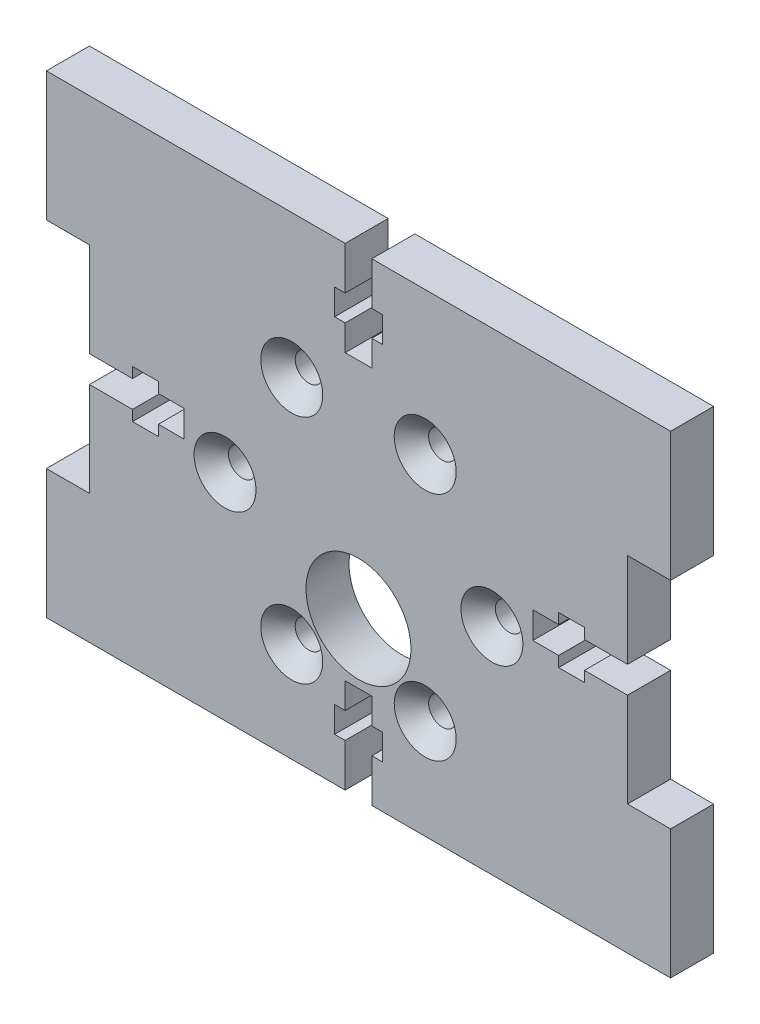
from build123d import *

# Parameters (mm, degrees)
ESQUISSE1_W                           = 26.253582595
ESQUISSE1_H                           = 55
BOSS_EXTRU_1_DEPTH                    = 5
BOSS_EXTRU_2_DEPTH                    = 5
BOSS_EXTRU_3_DEPTH                    = 5
ENL_V_MAT_EXTRU_1_DEPTH               = 5
ESQUISSE5_W                           = 5
ESQUISSE5_H                           = 50
BOSS_EXTRU_4_DEPTH                    = 36.246417405
BOSS_EXTRU_5_DEPTH                    = 5
BOSS_EXTRU_6_DEPTH                    = 5
BOSS_EXTRU_7_DEPTH                    = 5
DIAM_TRE_DU_PER_AGE_12_2_12_2_1_D     = 12.2
DIAM_TRE_DU_PER_AGE_12_2_12_2_1_DEPTH = 5
DIAM_TRE_DU_PER_AGE_3_2_3_2_1_D       = 3.2
CONG_1_R                              = 1.6
ESQUISSE13_W                          = 9.997056275
ESQUISSE13_H                          = 5
ESQUISSE13_W_2                        = 2.945778535
ESQUISSE13_W_3                        = 2.95
ESQUISSE13_W_4                        = 5
ESQUISSE13_H_2                        = 2.95
BOSS_EXTRU_8_DEPTH                    = 5
ENL_V_MAT_EXTRU_2_DEPTH               = 5
CHANFREIN1_SIZE                       = 2


with BuildPart() as part:
    # Esquisse1 → Boss.-Extru.1 (new body)
    with BuildSketch(Plane(origin=(0, 0, 0), x_dir=(-1, 0, 0), z_dir=(0, 0, -1))):
        with Locations((-18.123208703, 2.5)):
            Rectangle(ESQUISSE1_W, ESQUISSE1_H)
    extrude(amount=-BOSS_EXTRU_1_DEPTH)

    # Esquisse2 → Boss.-Extru.2 (add)
    with BuildSketch(Plane(origin=(31.25, 0, 0), x_dir=(0, 0, -1), z_dir=(1, 0, 0))):
        Polygon((0, 15), (-2.05, 15), (-5, 17.95), (-5, 30), (0, 30), align=None)
    extrude(amount=BOSS_EXTRU_2_DEPTH)

    # Esquisse3 → Boss.-Extru.3 (add)
    with BuildSketch(Plane(origin=(31.25, 0, 0), x_dir=(0, 0, -1), z_dir=(1, 0, 0))):
        Polygon((-5, -12.95), (-2.05, -10), (0, -10), (0, -25), (-5, -25), align=None)
    extrude(amount=BOSS_EXTRU_3_DEPTH)

    # Esquisse4 → Enlèv. mat.-Extru.1 (cut)
    with BuildSketch(Plane(origin=(0, 30, 0), x_dir=(-1, 0, 0), z_dir=(0, 1, 0))):
        Polygon((-4.996417405, 5), (-7.946417405, 5), (-4.996417405, 2.05), align=None)
    extrude(amount=-ENL_V_MAT_EXTRU_1_DEPTH, mode=Mode.SUBTRACT)

    # Esquisse5 → Boss.-Extru.4 (add)
    with BuildSketch(Plane.ZY.offset(-4.996417405)):
        with Locations((2.5, 0)):
            Rectangle(ESQUISSE5_W, ESQUISSE5_H)
    extrude(amount=BOSS_EXTRU_4_DEPTH)

    # Esquisse6 → Boss.-Extru.5 (add)
    with BuildSketch(Plane.ZY.offset(31.25)):
        Polygon((0, -25), (0, -10), (2.05, -10), (5, -12.95), (5, -25), align=None)
    extrude(amount=BOSS_EXTRU_5_DEPTH)

    # Esquisse7 → Boss.-Extru.6 (add)
    with BuildSketch(Plane.ZY.offset(31.25)):
        Polygon((0, 25), (5, 25), (5, 17.95), (2.05, 15), (0, 15), align=None)
    extrude(amount=BOSS_EXTRU_6_DEPTH)

    # Esquisse8 → Boss.-Extru.7 (add)
    with BuildSketch(Plane(origin=(0, 25, 0), x_dir=(-1, 0, 0), z_dir=(0, 1, 0))):
        Polygon((5.00063887, 2.054221466), (7.946417405, 5), (36.25, 5), (36.25, 0), (5.00063887, 0), align=None)
    extrude(amount=BOSS_EXTRU_7_DEPTH)

    # Diamètre du perçage Ø12.2 (12.2)1
    with Locations(Plane.XY.offset(5)):
        with Locations((0, -7)):
            Hole(DIAM_TRE_DU_PER_AGE_12_2_12_2_1_D / 2, depth=DIAM_TRE_DU_PER_AGE_12_2_12_2_1_DEPTH)

    # Diamètre du perçage Ø3.2 (3.2)1 (through all)
    with Locations(Plane.XY.offset(5)):
        with Locations((-7.75, -13.423393759), (15.5, 0), (-7.75, 13.423393759), (7.75, 13.423393759), (7.75, -13.423393759), (-15.5, 0)):
            Hole(DIAM_TRE_DU_PER_AGE_3_2_3_2_1_D / 2)

    # Congé1
    cong_1_edges = [part.edges().sort_by_distance(p)[0] for p in [
        (-5.00063887, 27.5, 2.054221466),
        (33.75, 15, 2.05),
        (33.75, -10, 2.05),
        (4.996417405, 27.5, 2.05),
        (-33.75, -10, 2.05),
        (-33.75, 15, 2.05),
    ]]
    fillet(cong_1_edges, radius=CONG_1_R)

    # Esquisse13 → Boss.-Extru.8 (add)
    with BuildSketch(Plane.XY.offset(5)):
        with Locations((-0.002110733, 27.5)):
            Rectangle(ESQUISSE13_W, ESQUISSE13_H)
        with Locations((-6.473528138, 27.5)):
            Rectangle(ESQUISSE13_W_2, ESQUISSE13_H)
        with Locations((6.471417405, 27.5)):
            Rectangle(ESQUISSE13_W_3, ESQUISSE13_H)
        with Locations((33.75, 16.475)):
            Rectangle(ESQUISSE13_W_4, ESQUISSE13_H_2)
        with Locations((33.75, -11.475)):
            Rectangle(ESQUISSE13_W_4, ESQUISSE13_H_2)
        with Locations((-33.75, -11.475)):
            Rectangle(ESQUISSE13_W_4, ESQUISSE13_H_2)
        with Locations((-33.75, 16.475)):
            Rectangle(ESQUISSE13_W_4, ESQUISSE13_H_2)
    extrude(amount=-BOSS_EXTRU_8_DEPTH)

    # Esquisse14 → Enlèv. mat.-Extru.2 (cut)
    with BuildSketch(Plane.XY.offset(5)):
        Polygon((-1.55, 19), (1.55, 19), (1.55, 22), (2.78, 22), (2.78, 25), (1.55, 25), (1.55, 30), (-1.55, 30), (-1.55, 25), (-2.77, 25), (-2.77, 22), (-1.55, 22), align=None)
        Polygon((-23.25, 0.95), (-20.25, 0.95), (-20.25, 4.05), (-23.25, 4.05), (-23.25, 5.27), (-26.25, 5.27), (-26.25, 4.05), (-31.25, 4.05), (-31.25, 0.95), (-26.25, 0.95), (-26.25, -0.28), (-23.25, -0.28), align=None)
        Polygon((23.25, -0.28), (26.25, -0.28), (26.25, 0.95), (31.25, 0.95), (31.25, 4.05), (26.25, 4.05), (26.25, 5.27), (23.25, 5.27), (23.25, 4.05), (20.25, 4.05), (20.25, 0.95), (23.25, 0.95), align=None)
        Polygon((-1.55, -17), (-2.77, -17), (-2.77, -20), (-1.55, -20), (-1.55, -25), (1.55, -25), (1.55, -20), (2.78, -20), (2.78, -17), (1.55, -17), (1.55, -14), (-1.55, -14), align=None)
    extrude(amount=-ENL_V_MAT_EXTRU_2_DEPTH, mode=Mode.SUBTRACT)

    # Chanfrein1
    chanfrein1_edges = [part.edges().sort_by_distance(p)[0] for p in [
        (-13.9, 0, 5),
        (9.35, -13.423393759, 5),
        (9.35, 13.423393759, 5),
        (-6.15, 13.423393759, 5),
        (17.1, 0, 5),
        (-6.15, -13.423393759, 5),
    ]]
    chamfer(chanfrein1_edges, length=CHANFREIN1_SIZE)


solid = part.part
